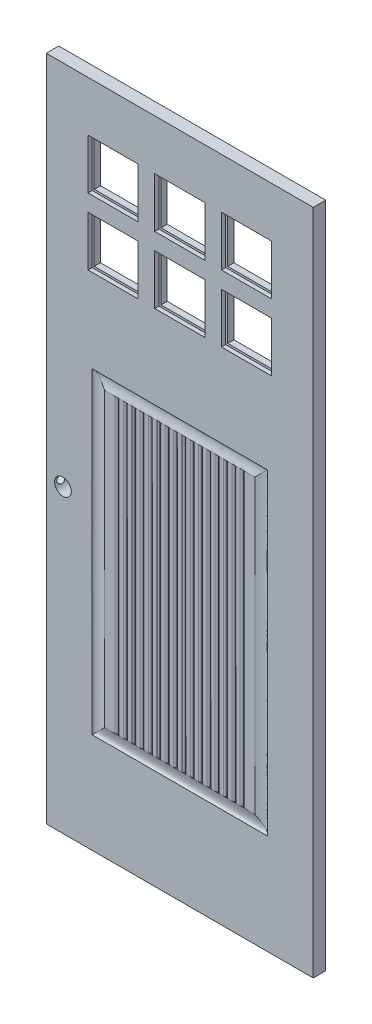
from build123d import *

# Parameters (mm, degrees)
SKETCH1_W               = 812.8
SKETCH1_H               = 2032
BOSS_EXTRUDE1_DEPTH     = 38.1
SKETCH2_R               = 25.4
SKETCH2_W               = 152.4
SKETCH2_H               = 152.4
CUT_EXTRUDE1_DEPTH      = 38.1
CUT_EXTRUDE2_REACH      = 814.8
SKETCH3_R               = 12.7
SKETCH9_W               = 571.5
SKETCH9_H               = 6.35
CUT_EXTRUDE3_DEPTH      = 361.95
CUT_EXTRUDE3_DEPTH_BACK = 6.35


with BuildPart() as part:
    # Sketch1 → Boss-Extrude1 (new body)
    with BuildSketch(Plane.XY):
        Rectangle(SKETCH1_W, SKETCH1_H)
    extrude(amount=BOSS_EXTRUDE1_DEPTH)

    # Sketch2 → Cut-Extrude1 (cut)
    with BuildSketch(Plane.XY.offset(38.1)):
        with Locations((-355.6, -101.6)):
            Circle(SKETCH2_R)
        with Locations((-203.2, 787.4)):
            Rectangle(SKETCH2_W, SKETCH2_H)
        with Locations((0, 787.4)):
            Rectangle(SKETCH2_W, SKETCH2_H)
        with Locations((203.2, 787.4)):
            Rectangle(SKETCH2_W, SKETCH2_H)
        with Locations((0, 584.2)):
            Rectangle(SKETCH2_W, SKETCH2_H)
        with Locations((203.2, 584.2)):
            Rectangle(SKETCH2_W, SKETCH2_H)
        with Locations((-203.2, 584.2)):
            Rectangle(SKETCH2_W, SKETCH2_H)
    extrude(amount=-CUT_EXTRUDE1_DEPTH, mode=Mode.SUBTRACT)

    # Sketch3 → Cut-Extrude2 (cut, up to next)
    with BuildSketch(Plane.ZY.offset(406.4), mode=Mode.PRIVATE) as cut_extrude2_sk1:
        with Locations((19.05, -101.6)):
            Circle(SKETCH3_R)
    cut_extrude2_tool1 = extrude(cut_extrude2_sk1.sketch, amount=-CUT_EXTRUDE2_REACH, mode=Mode.PRIVATE) & part.part
    add(cut_extrude2_tool1.solids().sort_by_distance((-406.4, -101.6, 19.05))[0], mode=Mode.SUBTRACT)

    # Cut-Sweep1: sweep along a path in Sketch4
    with BuildLine(Plane.XY.offset(38.1)) as cut_sweep1_path:
        Line((-266.7, 254), (266.7, 254))
        Line((266.7, 254), (266.7, -711.2))
        Line((266.7, -711.2), (-266.7, -711.2))
        Line((-266.7, -711.2), (-266.7, 254))
    # Sketch5 → Cut-Sweep1 (sweep, cut)
    with BuildSketch(Plane(origin=(0, 0, 0), x_dir=(0, 0, -1), z_dir=(1, 0, 0))):
        with BuildLine():
            Line((-38.1, 254), (-38.1, 215.9))
            add(Edge.make_bspline(
                [(-38.1, 215.9), (-37.720197072, 218.027481507), (-27.761997339, 241.906346411), (-34.857629478, 252.829210755), (-38.1, 254)],
                knots=[0.037171875, 0.037171875, 0.037171875, 0.037171875, 0.768062351, 1, 1, 1, 1], degree=3))
        make_face()
        with BuildLine():
            Line((0, 254), (0, 215.9))
            add(Edge.make_bspline(
                [(0, 215.9), (-0.379802928, 218.027481507), (-10.338002661, 241.906346411), (-3.242370522, 252.829210755), (0, 254)],
                knots=[0.037171875, 0.037171875, 0.037171875, 0.037171875, 0.768062351, 1, 1, 1, 1], degree=3))
        make_face()
    sweep(path=cut_sweep1_path.line, transition=Transition.RIGHT, mode=Mode.SUBTRACT)

    # Cut-Sweep4: sweep along a path in Sketch8
    with BuildLine(Plane.ZY.offset(406.4)) as cut_sweep4_path:
        Line((19.05, 215.9), (19.05, -673.1))
    # Sketch7 → Cut-Sweep4 (sweep, cut)
    with BuildSketch(Plane(origin=(0, 0, 0), x_dir=(1, 0, 0), z_dir=(0, 1, 0))):
        with BuildLine():
            Line((-184.15, -38.1), (-196.85, -38.1))
            add(Edge.make_bspline(
                [(-196.85, -38.1), (-191.560140262, -37.368366293), (-190.5, -31.75)],
                knots=[0, 0, 0, 1, 1, 1], degree=2))
            add(Edge.make_bspline(
                [(-184.15, -38.1), (-189.439859738, -37.368366293), (-190.5, -31.75)],
                knots=[0, 0, 0, 1, 1, 1], degree=2))
        make_face()
        with BuildLine():
            Line((-158.75, -38.1), (-171.45, -38.1))
            add(Edge.make_bspline(
                [(-171.45, -38.1), (-166.160140262, -37.368366293), (-165.1, -31.75)],
                knots=[0, 0, 0, 1, 1, 1], degree=2))
            add(Edge.make_bspline(
                [(-158.75, -38.1), (-164.039859738, -37.368366293), (-165.1, -31.75)],
                knots=[0, 0, 0, 1, 1, 1], degree=2))
        make_face()
        with BuildLine():
            Line((-133.35, -38.1), (-146.05, -38.1))
            add(Edge.make_bspline(
                [(-146.05, -38.1), (-140.760140262, -37.368366293), (-139.7, -31.75)],
                knots=[0, 0, 0, 1, 1, 1], degree=2))
            add(Edge.make_bspline(
                [(-133.35, -38.1), (-138.639859738, -37.368366293), (-139.7, -31.75)],
                knots=[0, 0, 0, 1, 1, 1], degree=2))
        make_face()
        with BuildLine():
            Line((-107.95, -38.1), (-120.65, -38.1))
            add(Edge.make_bspline(
                [(-120.65, -38.1), (-115.360140262, -37.368366293), (-114.3, -31.75)],
                knots=[0, 0, 0, 1, 1, 1], degree=2))
            add(Edge.make_bspline(
                [(-107.95, -38.1), (-113.239859738, -37.368366293), (-114.3, -31.75)],
                knots=[0, 0, 0, 1, 1, 1], degree=2))
        make_face()
        with BuildLine():
            Line((-82.55, -38.1), (-95.25, -38.1))
            add(Edge.make_bspline(
                [(-95.25, -38.1), (-89.960140262, -37.368366293), (-88.9, -31.75)],
                knots=[0, 0, 0, 1, 1, 1], degree=2))
            add(Edge.make_bspline(
                [(-82.55, -38.1), (-87.839859738, -37.368366293), (-88.9, -31.75)],
                knots=[0, 0, 0, 1, 1, 1], degree=2))
        make_face()
        with BuildLine():
            Line((-57.15, -38.1), (-69.85, -38.1))
            add(Edge.make_bspline(
                [(-69.85, -38.1), (-64.560140262, -37.368366293), (-63.5, -31.75)],
                knots=[0, 0, 0, 1, 1, 1], degree=2))
            add(Edge.make_bspline(
                [(-57.15, -38.1), (-62.439859738, -37.368366293), (-63.5, -31.75)],
                knots=[0, 0, 0, 1, 1, 1], degree=2))
        make_face()
        with BuildLine():
            Line((-31.75, -38.1), (-44.45, -38.1))
            add(Edge.make_bspline(
                [(-44.45, -38.1), (-39.160140262, -37.368366293), (-38.1, -31.75)],
                knots=[0, 0, 0, 1, 1, 1], degree=2))
            add(Edge.make_bspline(
                [(-31.75, -38.1), (-37.039859738, -37.368366293), (-38.1, -31.75)],
                knots=[0, 0, 0, 1, 1, 1], degree=2))
        make_face()
        with BuildLine():
            Line((-6.35, -38.1), (-19.05, -38.1))
            add(Edge.make_bspline(
                [(-19.05, -38.1), (-13.760140262, -37.368366293), (-12.7, -31.75)],
                knots=[0, 0, 0, 1, 1, 1], degree=2))
            add(Edge.make_bspline(
                [(-6.35, -38.1), (-11.639859738, -37.368366293), (-12.7, -31.75)],
                knots=[0, 0, 0, 1, 1, 1], degree=2))
        make_face()
        with BuildLine():
            Line((19.05, -38.1), (6.35, -38.1))
            add(Edge.make_bspline(
                [(6.35, -38.1), (11.639859738, -37.368366293), (12.7, -31.75)],
                knots=[0, 0, 0, 1, 1, 1], degree=2))
            add(Edge.make_bspline(
                [(19.05, -38.1), (13.760140262, -37.368366293), (12.7, -31.75)],
                knots=[0, 0, 0, 1, 1, 1], degree=2))
        make_face()
        with BuildLine():
            Line((44.45, -38.1), (31.75, -38.1))
            add(Edge.make_bspline(
                [(31.75, -38.1), (37.039859738, -37.368366293), (38.1, -31.75)],
                knots=[0, 0, 0, 1, 1, 1], degree=2))
            add(Edge.make_bspline(
                [(44.45, -38.1), (39.160140262, -37.368366293), (38.1, -31.75)],
                knots=[0, 0, 0, 1, 1, 1], degree=2))
        make_face()
        with BuildLine():
            Line((69.85, -38.1), (57.15, -38.1))
            add(Edge.make_bspline(
                [(57.15, -38.1), (62.439859738, -37.368366293), (63.5, -31.75)],
                knots=[0, 0, 0, 1, 1, 1], degree=2))
            add(Edge.make_bspline(
                [(69.85, -38.1), (64.560140262, -37.368366293), (63.5, -31.75)],
                knots=[0, 0, 0, 1, 1, 1], degree=2))
        make_face()
        with BuildLine():
            Line((95.25, -38.1), (82.55, -38.1))
            add(Edge.make_bspline(
                [(82.55, -38.1), (87.839859738, -37.368366293), (88.9, -31.75)],
                knots=[0, 0, 0, 1, 1, 1], degree=2))
            add(Edge.make_bspline(
                [(95.25, -38.1), (89.960140262, -37.368366293), (88.9, -31.75)],
                knots=[0, 0, 0, 1, 1, 1], degree=2))
        make_face()
        with BuildLine():
            Line((120.65, -38.1), (107.95, -38.1))
            add(Edge.make_bspline(
                [(107.95, -38.1), (113.239859738, -37.368366293), (114.3, -31.75)],
                knots=[0, 0, 0, 1, 1, 1], degree=2))
            add(Edge.make_bspline(
                [(120.65, -38.1), (115.360140262, -37.368366293), (114.3, -31.75)],
                knots=[0, 0, 0, 1, 1, 1], degree=2))
        make_face()
        with BuildLine():
            Line((146.05, -38.1), (133.35, -38.1))
            add(Edge.make_bspline(
                [(133.35, -38.1), (138.639859738, -37.368366293), (139.7, -31.75)],
                knots=[0, 0, 0, 1, 1, 1], degree=2))
            add(Edge.make_bspline(
                [(146.05, -38.1), (140.760140262, -37.368366293), (139.7, -31.75)],
                knots=[0, 0, 0, 1, 1, 1], degree=2))
        make_face()
        with BuildLine():
            Line((171.45, -38.1), (158.75, -38.1))
            add(Edge.make_bspline(
                [(158.75, -38.1), (164.039859738, -37.368366293), (165.1, -31.75)],
                knots=[0, 0, 0, 1, 1, 1], degree=2))
            add(Edge.make_bspline(
                [(171.45, -38.1), (166.160140262, -37.368366293), (165.1, -31.75)],
                knots=[0, 0, 0, 1, 1, 1], degree=2))
        make_face()
        with BuildLine():
            Line((196.85, -38.1), (184.15, -38.1))
            add(Edge.make_bspline(
                [(184.15, -38.1), (189.439859738, -37.368366293), (190.5, -31.75)],
                knots=[0, 0, 0, 1, 1, 1], degree=2))
            add(Edge.make_bspline(
                [(196.85, -38.1), (191.560140262, -37.368366293), (190.5, -31.75)],
                knots=[0, 0, 0, 1, 1, 1], degree=2))
        make_face()
        with BuildLine():
            Line((196.85, 0), (184.15, 0))
            add(Edge.make_bspline(
                [(184.15, 0), (189.439859738, -0.731633707), (190.5, -6.35)],
                knots=[0, 0, 0, 1, 1, 1], degree=2))
            add(Edge.make_bspline(
                [(196.85, 0), (191.560140262, -0.731633707), (190.5, -6.35)],
                knots=[0, 0, 0, 1, 1, 1], degree=2))
        make_face()
        with BuildLine():
            Line((171.45, 0), (158.75, 0))
            add(Edge.make_bspline(
                [(158.75, 0), (164.039859738, -0.731633707), (165.1, -6.35)],
                knots=[0, 0, 0, 1, 1, 1], degree=2))
            add(Edge.make_bspline(
                [(171.45, 0), (166.160140262, -0.731633707), (165.1, -6.35)],
                knots=[0, 0, 0, 1, 1, 1], degree=2))
        make_face()
        with BuildLine():
            Line((146.05, 0), (133.35, 0))
            add(Edge.make_bspline(
                [(133.35, 0), (138.639859738, -0.731633707), (139.7, -6.35)],
                knots=[0, 0, 0, 1, 1, 1], degree=2))
            add(Edge.make_bspline(
                [(146.05, 0), (140.760140262, -0.731633707), (139.7, -6.35)],
                knots=[0, 0, 0, 1, 1, 1], degree=2))
        make_face()
        with BuildLine():
            Line((120.65, 0), (107.95, 0))
            add(Edge.make_bspline(
                [(107.95, 0), (113.239859738, -0.731633707), (114.3, -6.35)],
                knots=[0, 0, 0, 1, 1, 1], degree=2))
            add(Edge.make_bspline(
                [(120.65, 0), (115.360140262, -0.731633707), (114.3, -6.35)],
                knots=[0, 0, 0, 1, 1, 1], degree=2))
        make_face()
        with BuildLine():
            Line((95.25, 0), (82.55, 0))
            add(Edge.make_bspline(
                [(82.55, 0), (87.839859738, -0.731633707), (88.9, -6.35)],
                knots=[0, 0, 0, 1, 1, 1], degree=2))
            add(Edge.make_bspline(
                [(95.25, 0), (89.960140262, -0.731633707), (88.9, -6.35)],
                knots=[0, 0, 0, 1, 1, 1], degree=2))
        make_face()
        with BuildLine():
            Line((69.85, 0), (57.15, 0))
            add(Edge.make_bspline(
                [(57.15, 0), (62.439859738, -0.731633707), (63.5, -6.35)],
                knots=[0, 0, 0, 1, 1, 1], degree=2))
            add(Edge.make_bspline(
                [(69.85, 0), (64.560140262, -0.731633707), (63.5, -6.35)],
                knots=[0, 0, 0, 1, 1, 1], degree=2))
        make_face()
        with BuildLine():
            Line((44.45, 0), (31.75, 0))
            add(Edge.make_bspline(
                [(31.75, 0), (37.039859738, -0.731633707), (38.1, -6.35)],
                knots=[0, 0, 0, 1, 1, 1], degree=2))
            add(Edge.make_bspline(
                [(44.45, 0), (39.160140262, -0.731633707), (38.1, -6.35)],
                knots=[0, 0, 0, 1, 1, 1], degree=2))
        make_face()
        with BuildLine():
            Line((19.05, 0), (6.35, 0))
            add(Edge.make_bspline(
                [(6.35, 0), (11.639859738, -0.731633707), (12.7, -6.35)],
                knots=[0, 0, 0, 1, 1, 1], degree=2))
            add(Edge.make_bspline(
                [(19.05, 0), (13.760140262, -0.731633707), (12.7, -6.35)],
                knots=[0, 0, 0, 1, 1, 1], degree=2))
        make_face()
        with BuildLine():
            Line((-6.35, 0), (-19.05, 0))
            add(Edge.make_bspline(
                [(-19.05, 0), (-13.760140262, -0.731633707), (-12.7, -6.35)],
                knots=[0, 0, 0, 1, 1, 1], degree=2))
            add(Edge.make_bspline(
                [(-6.35, 0), (-11.639859738, -0.731633707), (-12.7, -6.35)],
                knots=[0, 0, 0, 1, 1, 1], degree=2))
        make_face()
        with BuildLine():
            Line((-31.75, 0), (-44.45, 0))
            add(Edge.make_bspline(
                [(-44.45, 0), (-39.160140262, -0.731633707), (-38.1, -6.35)],
                knots=[0, 0, 0, 1, 1, 1], degree=2))
            add(Edge.make_bspline(
                [(-31.75, 0), (-37.039859738, -0.731633707), (-38.1, -6.35)],
                knots=[0, 0, 0, 1, 1, 1], degree=2))
        make_face()
        with BuildLine():
            Line((-57.15, 0), (-69.85, 0))
            add(Edge.make_bspline(
                [(-69.85, 0), (-64.560140262, -0.731633707), (-63.5, -6.35)],
                knots=[0, 0, 0, 1, 1, 1], degree=2))
            add(Edge.make_bspline(
                [(-57.15, 0), (-62.439859738, -0.731633707), (-63.5, -6.35)],
                knots=[0, 0, 0, 1, 1, 1], degree=2))
        make_face()
        with BuildLine():
            Line((-82.55, 0), (-95.25, 0))
            add(Edge.make_bspline(
                [(-95.25, 0), (-89.960140262, -0.731633707), (-88.9, -6.35)],
                knots=[0, 0, 0, 1, 1, 1], degree=2))
            add(Edge.make_bspline(
                [(-82.55, 0), (-87.839859738, -0.731633707), (-88.9, -6.35)],
                knots=[0, 0, 0, 1, 1, 1], degree=2))
        make_face()
        with BuildLine():
            Line((-107.95, 0), (-120.65, 0))
            add(Edge.make_bspline(
                [(-120.65, 0), (-115.360140262, -0.731633707), (-114.3, -6.35)],
                knots=[0, 0, 0, 1, 1, 1], degree=2))
            add(Edge.make_bspline(
                [(-107.95, 0), (-113.239859738, -0.731633707), (-114.3, -6.35)],
                knots=[0, 0, 0, 1, 1, 1], degree=2))
        make_face()
        with BuildLine():
            Line((-133.35, 0), (-146.05, 0))
            add(Edge.make_bspline(
                [(-146.05, 0), (-140.760140262, -0.731633707), (-139.7, -6.35)],
                knots=[0, 0, 0, 1, 1, 1], degree=2))
            add(Edge.make_bspline(
                [(-133.35, 0), (-138.639859738, -0.731633707), (-139.7, -6.35)],
                knots=[0, 0, 0, 1, 1, 1], degree=2))
        make_face()
        with BuildLine():
            Line((-158.75, 0), (-171.45, 0))
            add(Edge.make_bspline(
                [(-171.45, 0), (-166.160140262, -0.731633707), (-165.1, -6.35)],
                knots=[0, 0, 0, 1, 1, 1], degree=2))
            add(Edge.make_bspline(
                [(-158.75, 0), (-164.039859738, -0.731633707), (-165.1, -6.35)],
                knots=[0, 0, 0, 1, 1, 1], degree=2))
        make_face()
        with BuildLine():
            Line((-184.15, 0), (-196.85, 0))
            add(Edge.make_bspline(
                [(-196.85, 0), (-191.560140262, -0.731633707), (-190.5, -6.35)],
                knots=[0, 0, 0, 1, 1, 1], degree=2))
            add(Edge.make_bspline(
                [(-184.15, 0), (-189.439859738, -0.731633707), (-190.5, -6.35)],
                knots=[0, 0, 0, 1, 1, 1], degree=2))
        make_face()
    sweep(path=cut_sweep4_path.line, mode=Mode.SUBTRACT)

    # Sketch9 → Cut-Extrude3 (cut, two sides)
    with BuildSketch(Plane(origin=(0, 508, 0), x_dir=(1, 0, 0), z_dir=(0, 1, 0))) as cut_extrude3_sk:
        with Locations((0, -22.225)):
            Rectangle(SKETCH9_W, SKETCH9_H)
    extrude(amount=CUT_EXTRUDE3_DEPTH, mode=Mode.SUBTRACT)
    extrude(cut_extrude3_sk.sketch, amount=-CUT_EXTRUDE3_DEPTH_BACK, mode=Mode.SUBTRACT)


solid = part.part
